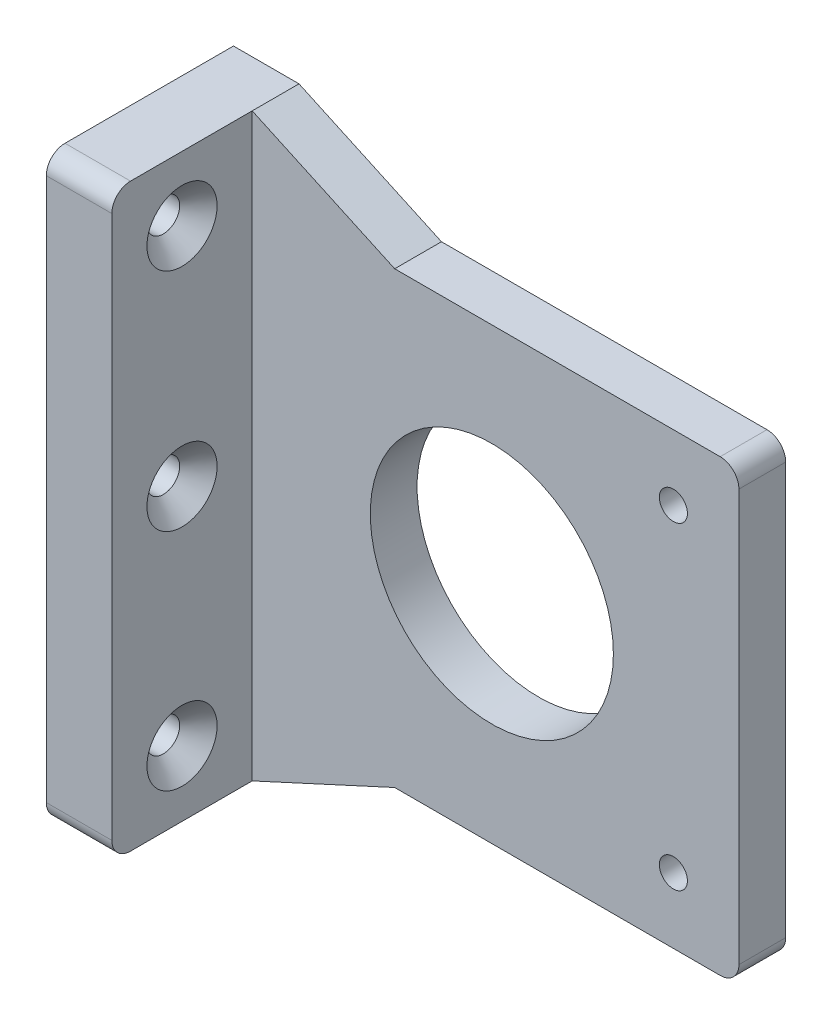
from build123d import *

# Parameters (mm, degrees)
SKETCH1_R           = 1.5
BOSS_EXTRUDE1_DEPTH = 5
SKETCH1_3_W         = 7
SKETCH1_3_H         = 62
BOSS_EXTRUDE2_DEPTH = 20
CUT_EXTRUDE1_DEPTH  = 18
CHAMFER1_SIZE       = 2
FILLET1_R           = 2
SKETCH3_R           = 12.986330219
CUT_EXTRUDE2_DEPTH  = 10


with BuildPart() as part:
    # Sketch1 → Boss-Extrude1 (new body)
    with BuildSketch(Plane.XY):
        Polygon((-62.777714162, 0), (-26, 0), (-26, 48), (-62.777714162, 48), (-78, 55), (-85, 55), (-85, -7), (-78, -7), align=None)
        with Locations((-33, 7)):
            Circle(SKETCH1_R, mode=Mode.SUBTRACT)
        with Locations((-33, 41)):
            Circle(SKETCH1_R, mode=Mode.SUBTRACT)
    extrude(amount=BOSS_EXTRUDE1_DEPTH)

    # Sketch1_3 → Boss-Extrude2 (add)
    with BuildSketch(Plane.XY):
        with Locations((-81.5, 24)):
            Rectangle(SKETCH1_3_W, SKETCH1_3_H)
    extrude(amount=BOSS_EXTRUDE2_DEPTH)

    # Sketch2 → Cut-Extrude1 (cut)
    with BuildSketch(Plane(origin=(-78, 0, 0), x_dir=(0, 0, -1), z_dir=(1, 0, 0))):
        with BuildLine():
            ThreePointArc((-12.5, 1.75), (-14.25, 0), (-12.5, -1.75))
            Line((-12.5, -1.75), (-12.5, 1.75))
        make_face()
        with BuildLine():
            Line((-12.5, 1.75), (-12.5, -1.75))
            ThreePointArc((-12.5, -1.75), (-11.262563133, -1.237436867), (-10.75, 0))
            ThreePointArc((-10.75, 0), (-11.262563133, 1.237436867), (-12.5, 1.75))
        make_face()
        with BuildLine():
            ThreePointArc((-12.5, 25.75), (-14.25, 24), (-12.5, 22.25))
            Line((-12.5, 22.25), (-12.5, 25.75))
        make_face()
        with BuildLine():
            Line((-12.5, 25.75), (-12.5, 22.25))
            ThreePointArc((-12.5, 22.25), (-11.262563133, 22.762563133), (-10.75, 24))
            ThreePointArc((-10.75, 24), (-11.262563133, 25.237436867), (-12.5, 25.75))
        make_face()
        with BuildLine():
            ThreePointArc((-12.5, 49.856077649), (-14.25, 48.106077649), (-12.5, 46.356077649))
            Line((-12.5, 46.356077649), (-12.5, 49.856077649))
        make_face()
        with BuildLine():
            Line((-12.5, 49.856077649), (-12.5, 46.356077649))
            ThreePointArc((-12.5, 46.356077649), (-11.262563133, 46.868640782), (-10.75, 48.106077649))
            ThreePointArc((-10.75, 48.106077649), (-11.262563133, 49.343514516), (-12.5, 49.856077649))
        make_face()
    extrude(amount=-CUT_EXTRUDE1_DEPTH, mode=Mode.SUBTRACT)

    # Chamfer1
    chamfer1_edges = [part.edges().sort_by_distance(p)[0] for p in [
        (-78, 1.75, 12.5),
        (-78, 25.75, 12.5),
        (-78, 49.856077649, 12.5),
    ]]
    chamfer(chamfer1_edges, length=CHAMFER1_SIZE)

    # Fillet1
    fillet1_edges = [part.edges().sort_by_distance(p)[0] for p in [
        (-26, 48, 2.5),
        (-26, 0, 2.5),
        (-81.5, 55, 20),
        (-81.5, -7, 20),
    ]]
    fillet(fillet1_edges, radius=FILLET1_R)

    # Sketch3 → Cut-Extrude2 (cut)
    with BuildSketch(Plane.XY.offset(5)):
        with Locations((-52.397587833, 24.041466389)):
            Circle(SKETCH3_R)
    extrude(amount=-CUT_EXTRUDE2_DEPTH, mode=Mode.SUBTRACT)


solid = part.part
